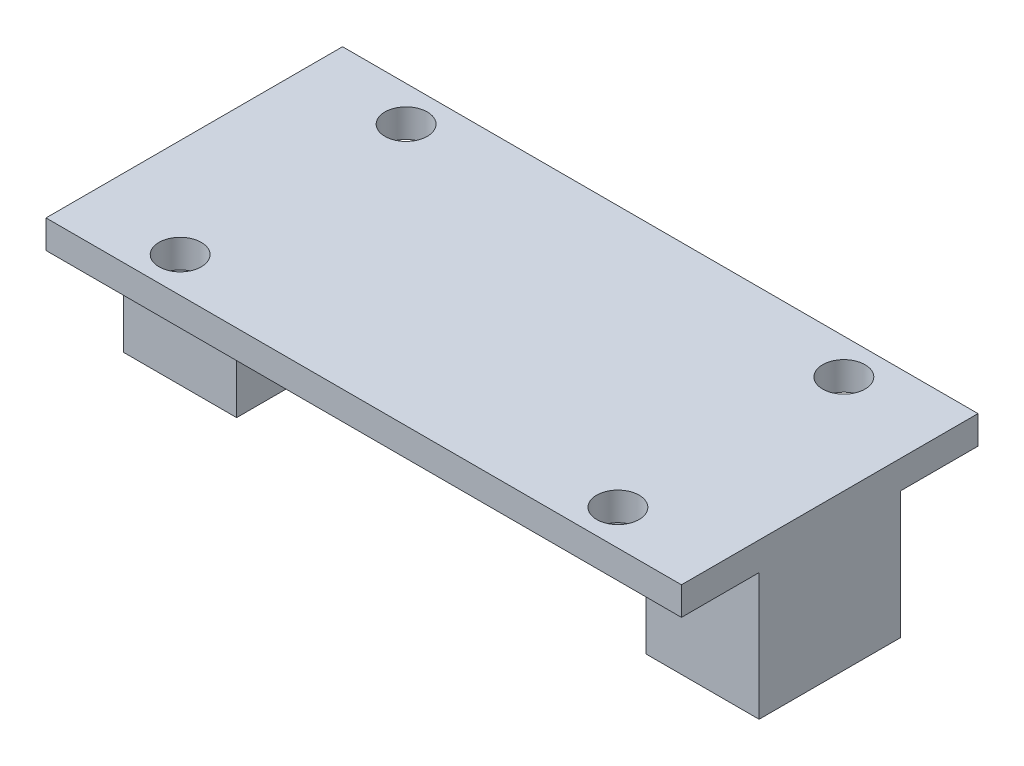
from build123d import *

# Parameters (mm, degrees)
BOSS_EXTRUDE1_DEPTH = 10
SKETCH3_W           = 45
SKETCH3_H           = 21
BOSS_EXTRUDE2_DEPTH = 2
SKETCH4_R           = 1.5
CUT_EXTRUDE1_DEPTH  = 5


with BuildPart() as part:
    # Sketch2 → Boss-Extrude1 (new body)
    with BuildSketch(Plane.XY):
        Polygon((-17.5, 0), (-17.5, -1), (-14.5, -1), (-14.5, -5), (-22.5, -5), (-22.5, 0), (-22.5, 4), (22.5, 4), (22.5, -5), (14.5, -5), (14.5, -1), (17.5, -1), (17.5, 0), align=None)
    extrude(amount=BOSS_EXTRUDE1_DEPTH)

    # Sketch3 → Boss-Extrude2 (add)
    with BuildSketch(Plane(origin=(0, 4, 0), x_dir=(1, 0, 0), z_dir=(0, 1, 0))):
        with Locations((0, -5)):
            Rectangle(SKETCH3_W, SKETCH3_H)
    extrude(amount=BOSS_EXTRUDE2_DEPTH)

    # Sketch4 → Cut-Extrude1 (cut)
    with BuildSketch(Plane(origin=(0, 6, 0), x_dir=(1, 0, 0), z_dir=(0, 1, 0))):
        with Locations((-15.5, -13)):
            Circle(SKETCH4_R)
        with Locations((-15.5, 3)):
            Circle(SKETCH4_R)
        with Locations((15.5, 3)):
            Circle(SKETCH4_R)
        with Locations((15.5, -13)):
            Circle(SKETCH4_R)
    extrude(amount=-CUT_EXTRUDE1_DEPTH, mode=Mode.SUBTRACT)


solid = part.part
